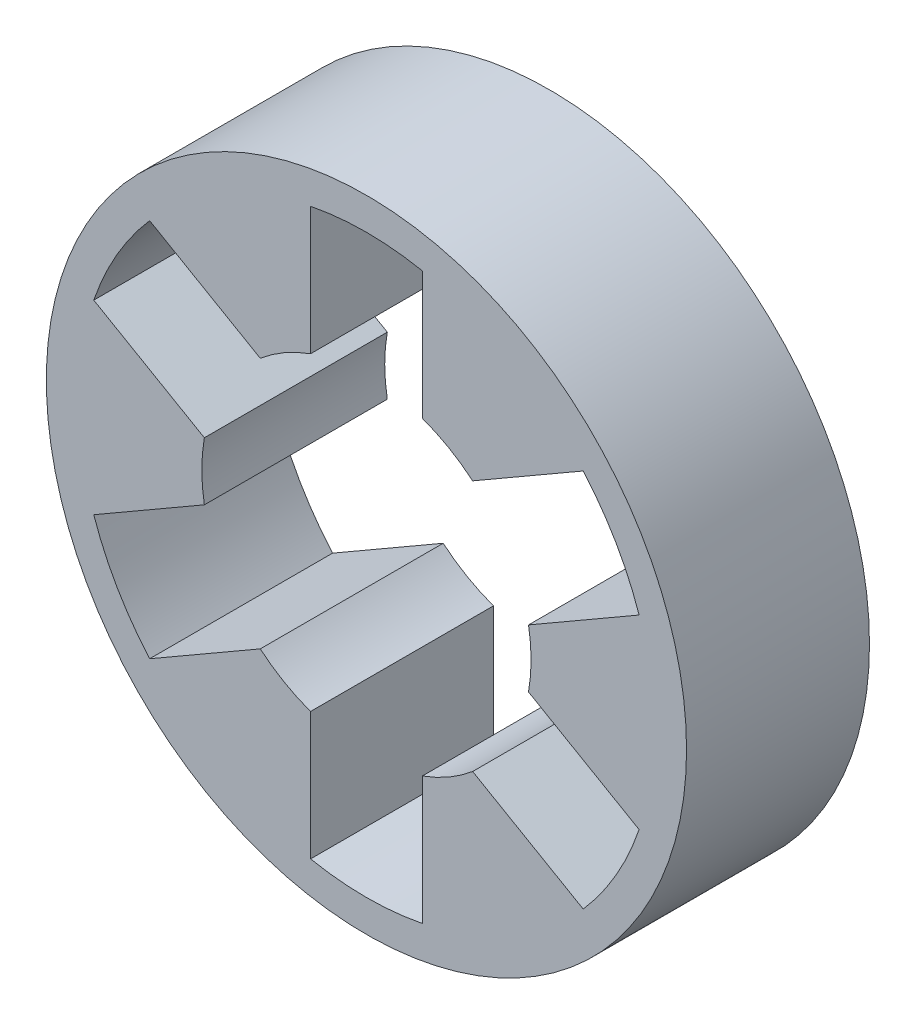
from build123d import *

# Parameters (mm, degrees)
SKETCH1_R           = 27.78125
SKETCH1_R_2         = 14.29
BOSS_EXTRUDE1_DEPTH = 15.875
CUT_EXTRUDE1_DEPTH  = 16.875


with BuildPart() as part:
    # Sketch1 → Boss-Extrude1 (new body)
    with BuildSketch(Plane.XY):
        Circle(SKETCH1_R)
        Circle(SKETCH1_R_2, mode=Mode.SUBTRACT)
    extrude(amount=BOSS_EXTRUDE1_DEPTH)

    # Sketch3 → Cut-Extrude1 (cut, through all)
    with BuildSketch(Plane.XY.offset(15.875)):
        with BuildLine():
            Line((18.814306165, -16.462742285), (4.849999952, -8.400446334))
            Line((4.849999952, -8.400446334), (4.849999952, -24.525038236))
            ThreePointArc((4.849999952, -24.525038236), (-4.9e-08, -25), (-4.850000048, -24.525038217))
            Line((-4.850000048, -24.525038217), (-4.850000048, -8.4004465))
            Line((-4.850000048, -8.4004465), (-18.814306101, -16.462742358))
            ThreePointArc((-18.814306101, -16.462742358), (-21.65063507, -12.500000042), (-23.664306117, -8.062295951))
            Line((-23.664306117, -8.062295951), (-9.699999904, 0))
            Line((-9.699999904, 0), (-23.664306117, 8.062295951))
            ThreePointArc((-23.664306117, 8.062295951), (-21.65063507, 12.500000042), (-18.814306101, 16.462742358))
            Line((-18.814306101, 16.462742358), (-4.850000048, 8.4004465))
            Line((-4.850000048, 8.4004465), (-4.850000048, 24.525038217))
            ThreePointArc((-4.850000048, 24.525038217), (-4.9e-08, 25), (4.849999952, 24.525038236))
            Line((4.849999952, 24.525038236), (4.849999952, 8.400446334))
            Line((4.849999952, 8.400446334), (18.814306165, 16.462742285))
            ThreePointArc((18.814306165, 16.462742285), (21.650635119, 12.499999958), (23.664306149, 8.062295858))
            Line((23.664306149, 8.062295858), (9.700000096, 0))
            Line((9.700000096, 0), (23.664306149, -8.062295858))
            ThreePointArc((23.664306149, -8.062295858), (21.650635119, -12.499999958), (18.814306165, -16.462742285))
        make_face()
    extrude(amount=-CUT_EXTRUDE1_DEPTH, mode=Mode.SUBTRACT)


solid = part.part
